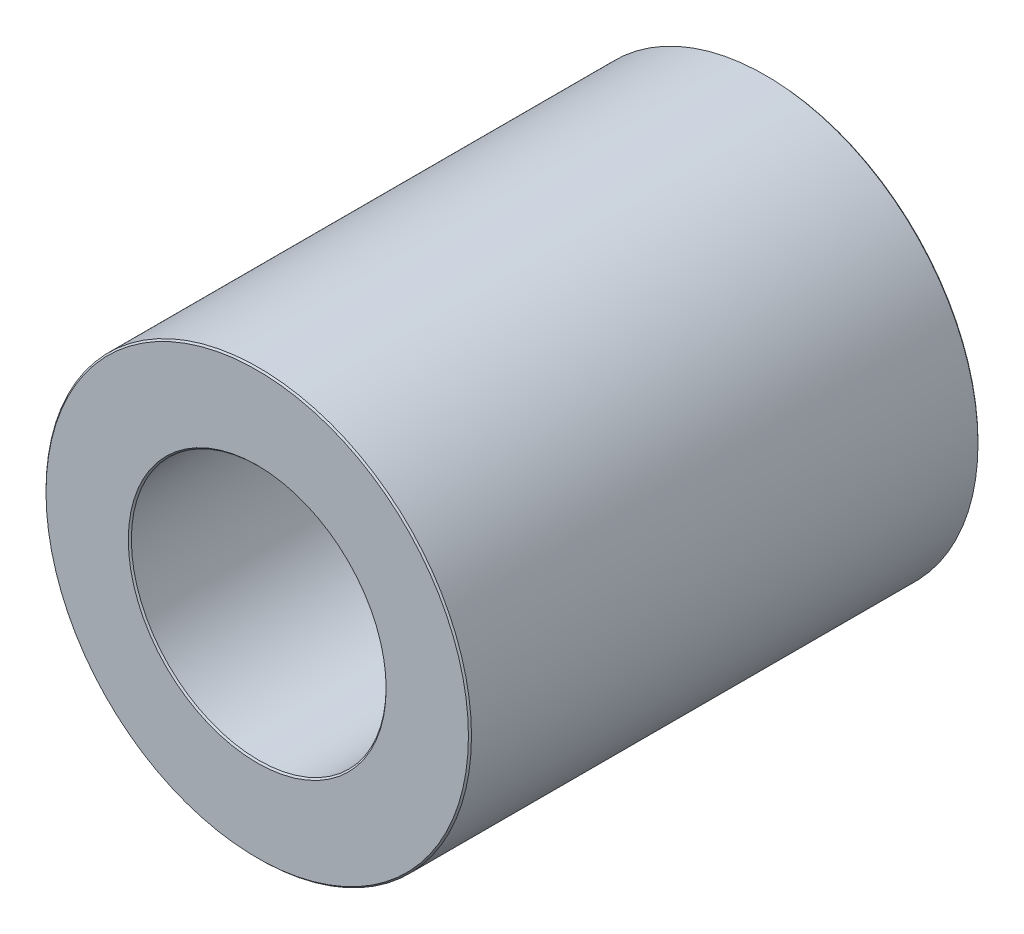
from build123d import *

# Parameters (mm, degrees)
SKETCH5_R                = 5.01
SKETCH5_R_2              = 3
BOSS_EXTRUDE1_DEPTH      = 6
BOSS_EXTRUDE1_DEPTH_BACK = 6
CHAMFER1_SIZE            = 0.036


with BuildPart() as part:
    # Sketch5 → Boss-Extrude1 (new body, two sides)
    with BuildSketch(Plane.XY) as boss_extrude1_sk:
        Circle(SKETCH5_R)
        Circle(SKETCH5_R_2, mode=Mode.SUBTRACT)
    extrude(amount=BOSS_EXTRUDE1_DEPTH)
    extrude(boss_extrude1_sk.sketch, amount=-BOSS_EXTRUDE1_DEPTH_BACK)

    # Chamfer1
    chamfer1_edges = [part.edges().sort_by_distance(p)[0] for p in [
        (-5.01, 0, 6),
        (-3, 0, 6),
        (-5.01, 0, -6),
        (-3, 0, -6),
    ]]
    chamfer(chamfer1_edges, length=CHAMFER1_SIZE)


solid = part.part
